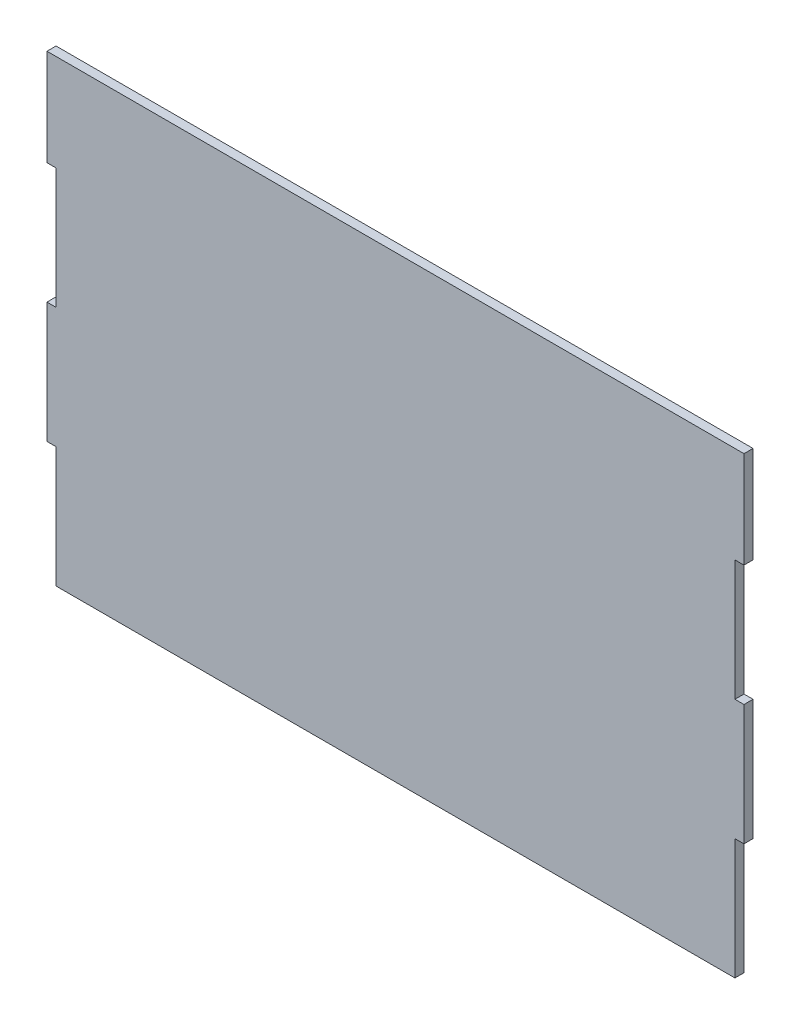
from build123d import *

# Parameters (mm, degrees)
BOSS_EXTRUDE1_DEPTH = 3


with BuildPart() as part:
    # Sketch1 → Boss-Extrude1 (new body)
    with BuildSketch(Plane.XY):
        Polygon((-112.5, 20), (-115.5, 20), (-115.5, -20), (-112.5, -20), (-112.5, -60), (112.5, -60), (112.5, -20), (115.5, -20), (115.5, 20), (112.5, 20), (112.5, 60), (115.5, 60), (115.5, 92), (112.5, 92), (-112.5, 92), (-115.5, 92), (-115.5, 60), (-112.5, 60), align=None)
    extrude(amount=BOSS_EXTRUDE1_DEPTH)


solid = part.part
